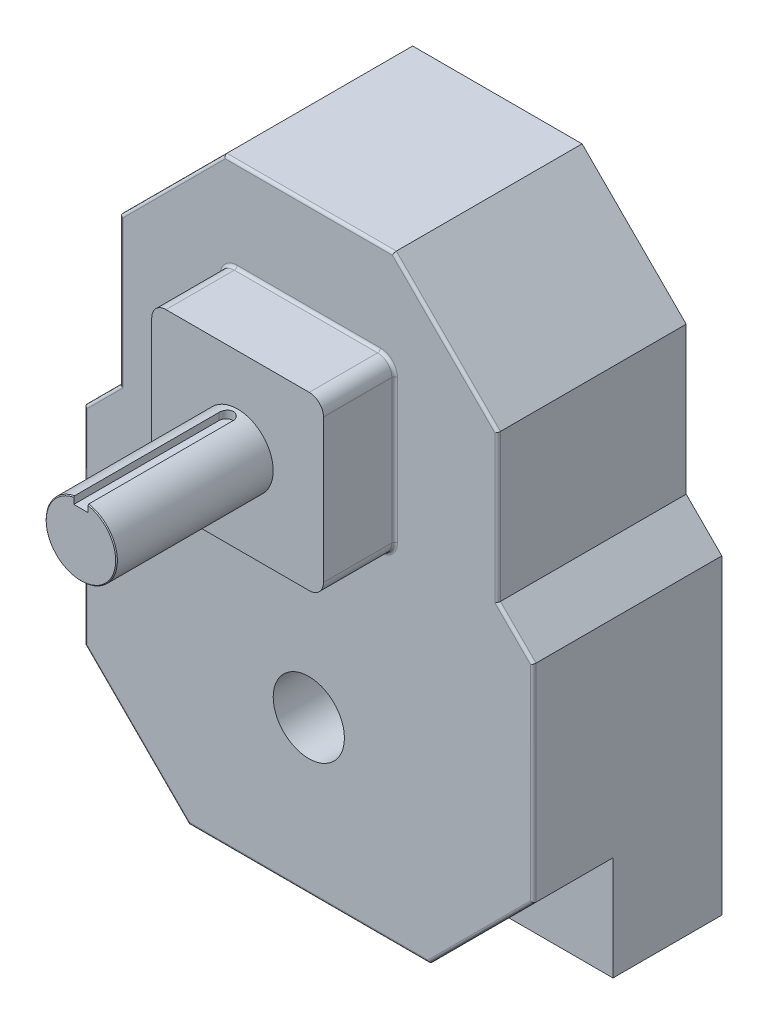
from build123d import *

# Parameters (mm, degrees)
BOSS_EXTRUDE1_DEPTH = 84.074
SKETCH3_W           = 76.581
SKETCH3_H           = 76.581
BOSS_EXTRUDE2_DEPTH = 31.75
SKETCH_D_R          = 15.875
BOSS_EXTRUDE3_DEPTH = 69.85
CUT_EXTRUDE1_DEPTH  = 35.56
FILLET1_R           = 6.35
FILLET2_R           = 1.27
KEYWAY_START        = 12.3698
KEYWAY_DEPTH        = 67.8782
CHAMFER1_SIZE       = 0.381
SKETCH7_R           = 15.875
CUT_EXTRUDE3_DEPTH  = 186.674


with BuildPart() as part:
    # L,M → Boss-Extrude1 (new body)
    with BuildSketch(Plane.XY):
        Polygon((-100.076, 68.326), (100.076, 68.326), (100.076, 207.077403609), (84.201, 222.952403609), (84.201, 288.603596391), (37.778596391, 335.026), (-37.778596391, 335.026), (-84.201, 288.603596391), (-84.201, 222.952403609), (-100.076, 207.077403609), align=None)
    extrude(amount=BOSS_EXTRUDE1_DEPTH)

    # Sketch3 → Boss-Extrude2 (add)
    with BuildSketch(Plane.XY.offset(84.074)):
        with Locations((0, 255.778)):
            Rectangle(SKETCH3_W, SKETCH3_H)
    extrude(amount=BOSS_EXTRUDE2_DEPTH)

    # D → Boss-Extrude3 (add)
    with BuildSketch(Plane.XY.offset(115.824)):
        with Locations((0, 255.778)):
            Circle(SKETCH_D_R)
    extrude(amount=BOSS_EXTRUDE3_DEPTH)

    # Sketch5 → Cut-Extrude1 (cut)
    with BuildSketch(Plane.XY.offset(84.074)):
        Polygon((100.076, 114.748403609), (53.653596391, 68.326), (100.076, 68.326), align=None)
        Polygon((-100.076, 68.326), (-100.076, 114.748403609), (-53.653596391, 68.326), align=None)
    extrude(amount=-CUT_EXTRUDE1_DEPTH, mode=Mode.SUBTRACT)

    # Fillet1
    fillet1_edges = [part.edges().sort_by_distance(p)[0] for p in [
        (-38.2905, 294.0685, 99.949),
        (-38.2905, 217.4875, 99.949),
        (38.2905, 217.4875, 99.949),
        (38.2905, 294.0685, 99.949),
    ]]
    fillet(fillet1_edges, radius=FILLET1_R)

    # Fillet2
    fillet2_edges = [part.edges().sort_by_distance(p)[0] for p in [
        (100.076, 160.912903609, 84.074),
        (76.864798195, 91.537201805, 84.074),
        (92.1385, 215.014903609, 84.074),
        (84.201, 255.778, 84.074),
        (60.989798195, 311.814798195, 84.074),
        (0, 335.026, 84.074),
        (0, 68.326, 84.074),
        (-60.989798195, 311.814798195, 84.074),
        (-84.201, 255.778, 84.074),
        (-92.1385, 215.014903609, 84.074),
        (-100.076, 160.912903609, 84.074),
        (-76.864798195, 91.537201805, 84.074),
        (0, 217.4875, 84.074),
        (-38.2905, 255.778, 84.074),
        (38.2905, 255.778, 84.074),
        (0, 294.0685, 84.074),
        (-36.430628061, 219.347371939, 84.074),
        (36.430628061, 219.347371939, 84.074),
        (-36.430628061, 292.208628061, 84.074),
        (36.430628061, 292.208628061, 84.074),
    ]]
    fillet(fillet2_edges, radius=FILLET2_R)

    # Sketch6 → Keyway (cut, through all)
    with BuildSketch(Plane(origin=(0, 255.778, 0), x_dir=(-1, 0, 0), z_dir=(0, 1, 0)).offset(KEYWAY_START)):
        with BuildLine():
            Line((3.175, 185.674), (3.175, 120.904))
            ThreePointArc((3.175, 120.904), (0, 117.729), (-3.175, 120.904))
            Line((-3.175, 120.904), (-3.175, 185.674))
            ThreePointArc((-3.175, 185.674), (0, 188.849), (3.175, 185.674))
        make_face()
    extrude(amount=KEYWAY_DEPTH, mode=Mode.SUBTRACT)

    # Chamfer1
    chamfer1_edges = [part.edges().sort_by_distance(p)[0] for p in [
        (-10.040231571, 243.481277876, 185.674),
    ]]
    chamfer(chamfer1_edges, length=CHAMFER1_SIZE)

    # Sketch7 → Cut-Extrude3 (cut, through all)
    with BuildSketch(Plane(origin=(0, 0, 0), x_dir=(-1, 0, 0), z_dir=(0, 0, -1))):
        with Locations((0, 136.652)):
            Circle(SKETCH7_R)
    extrude(amount=-CUT_EXTRUDE3_DEPTH, mode=Mode.SUBTRACT)


solid = part.part
